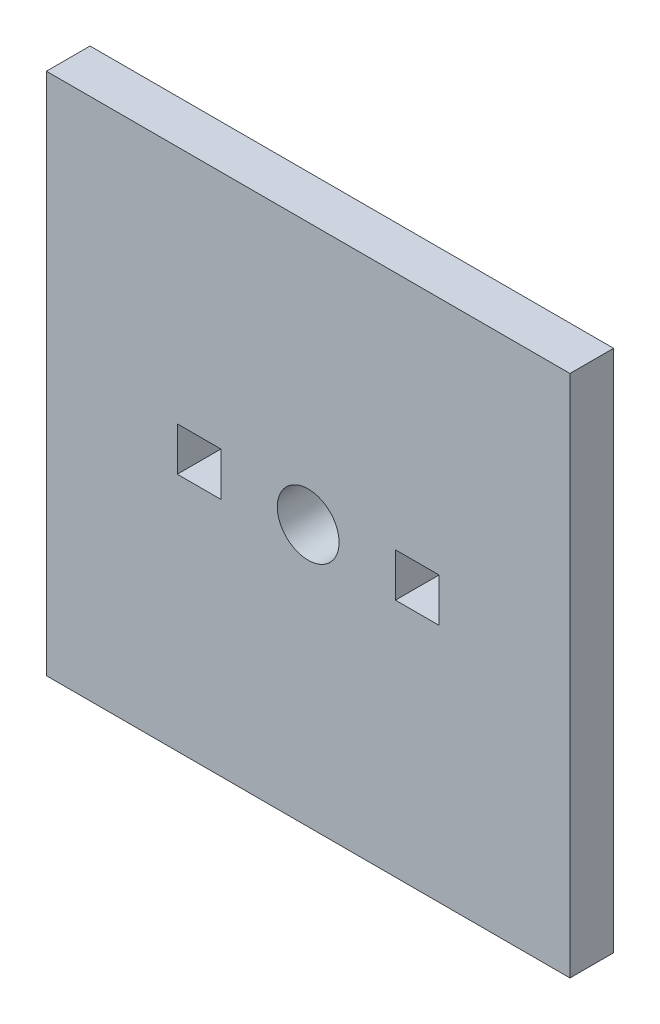
from build123d import *

# Parameters (mm, degrees)
SKETCH1_W                 = 38.1
SKETCH1_H                 = 38.1
BOSS_EXTRUDE1_DEPTH       = 3.175
F_8_CLEARANCE_HOLE1_D     = 4.4958
F_8_CLEARANCE_HOLE1_DEPTH = 10.16
F_8_CLEARANCE_HOLE1_TIP   = 1.350674586
SKETCH4_W                 = 3.175
SKETCH4_H                 = 3.175
CUT_EXTRUDE1_DEPTH        = 3.175


with BuildPart() as part:
    # Sketch1 → Boss-Extrude1 (new body)
    with BuildSketch(Plane.XY):
        Rectangle(SKETCH1_W, SKETCH1_H)
    extrude(amount=BOSS_EXTRUDE1_DEPTH)

    # #8 Clearance Hole1
    with Locations(Plane.XY.offset(3.175)):
        with Locations((0, 0)):
            Hole(F_8_CLEARANCE_HOLE1_D / 2, depth=F_8_CLEARANCE_HOLE1_DEPTH)
            with Locations((0, 0, -(F_8_CLEARANCE_HOLE1_DEPTH + F_8_CLEARANCE_HOLE1_TIP / 2))):  # 118° drill point
                Cone(0, F_8_CLEARANCE_HOLE1_D / 2, F_8_CLEARANCE_HOLE1_TIP, mode=Mode.SUBTRACT)

    # Sketch4 → Cut-Extrude1 (cut)
    with BuildSketch(Plane.XY.offset(3.175)):
        with Locations((-7.9375, 0)):
            Rectangle(SKETCH4_W, SKETCH4_H)
        with Locations((7.9375, 0)):
            Rectangle(SKETCH4_W, SKETCH4_H)
    extrude(amount=-CUT_EXTRUDE1_DEPTH, mode=Mode.SUBTRACT)


solid = part.part
